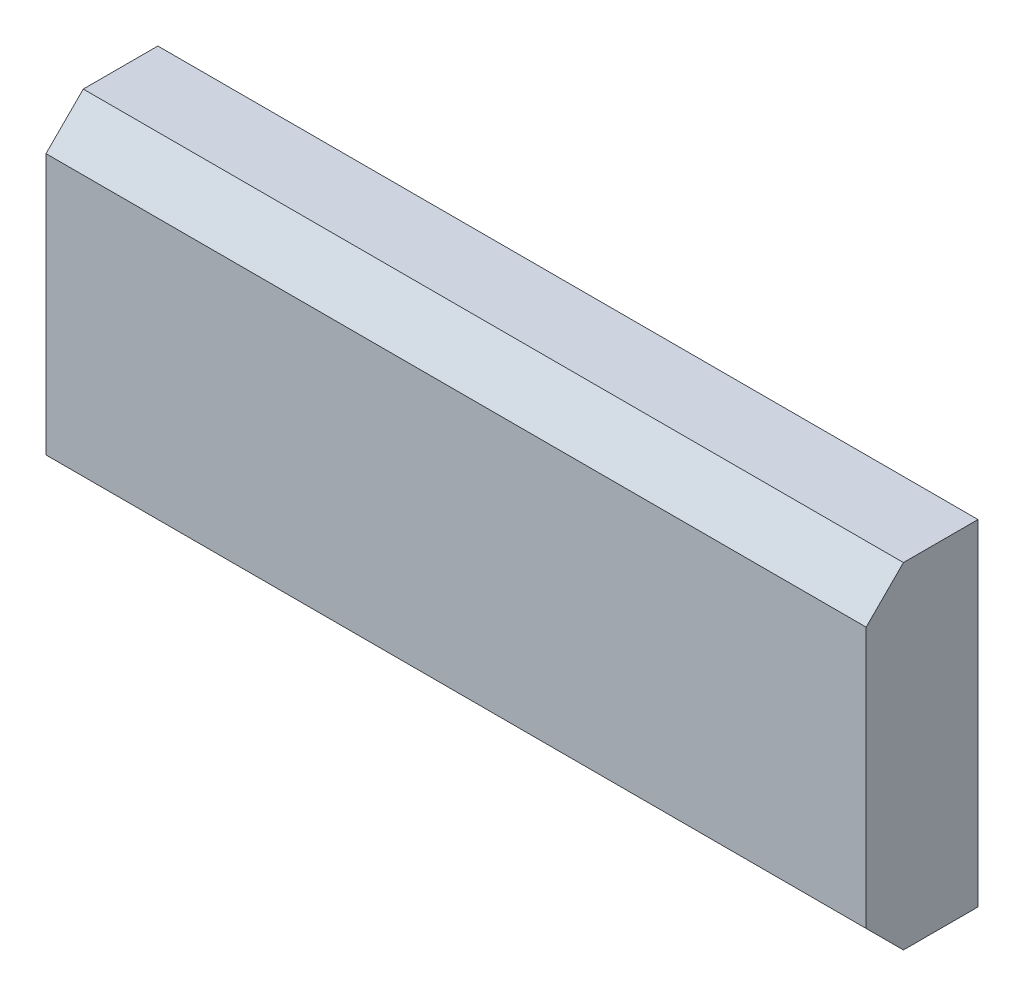
from build123d import *

# Parameters (mm, degrees)
SKETCH_1_W      = 22
SKETCH_1_H      = 9
EXTRUDE_1_DEPTH = 3
CHAMFER_1_SIZE  = 1


with BuildPart() as part:
    # Эскиз1 → Вытянуть1 (new body)
    with BuildSketch(Plane.XY):
        Rectangle(SKETCH_1_W, SKETCH_1_H)
    extrude(amount=EXTRUDE_1_DEPTH)

    # Фаска1
    chamfer_1_edges = [part.edges().sort_by_distance(p)[0] for p in [
        (0, 4.5, 3),
        (0, -4.5, 3),
    ]]
    chamfer(chamfer_1_edges, length=CHAMFER_1_SIZE)


solid = part.part
